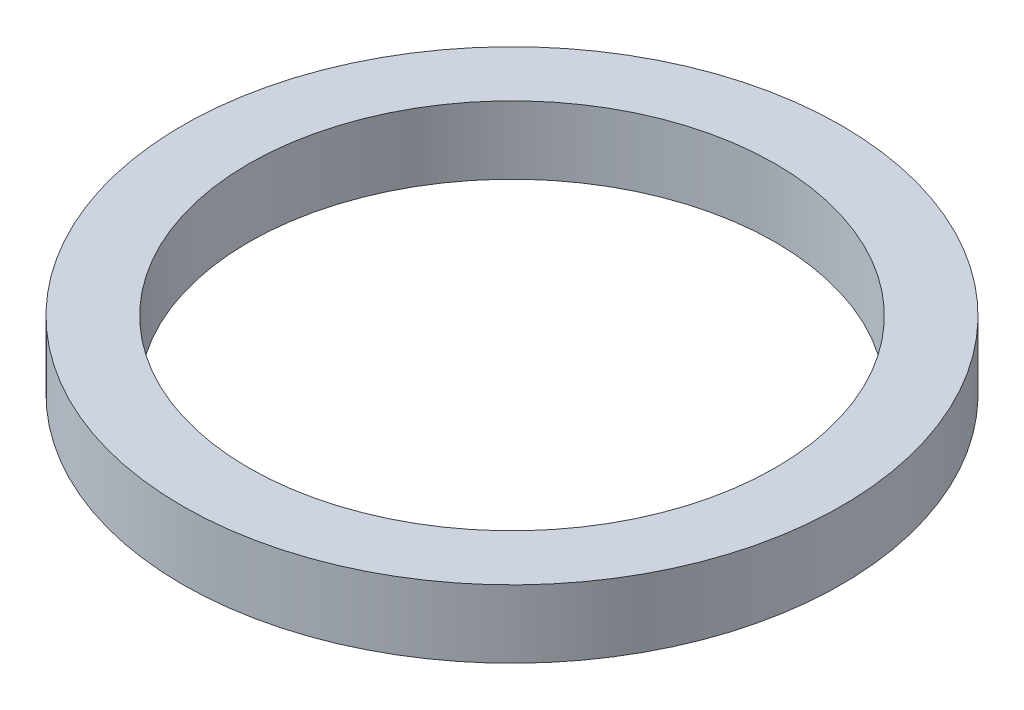
from build123d import *

# Parameters (mm, degrees)
SKETCH1_R           = 12.7
SKETCH1_R_2         = 10.1473
BOSS_EXTRUDE1_DEPTH = 2.6162


with BuildPart() as part:
    # Sketch1 → Boss-Extrude1 (new body)
    with BuildSketch(Plane(origin=(0, 0, 0), x_dir=(1, 0, 0), z_dir=(0, 1, 0))):
        Circle(SKETCH1_R)
        Circle(SKETCH1_R_2, mode=Mode.SUBTRACT)
    extrude(amount=BOSS_EXTRUDE1_DEPTH)


solid = part.part
